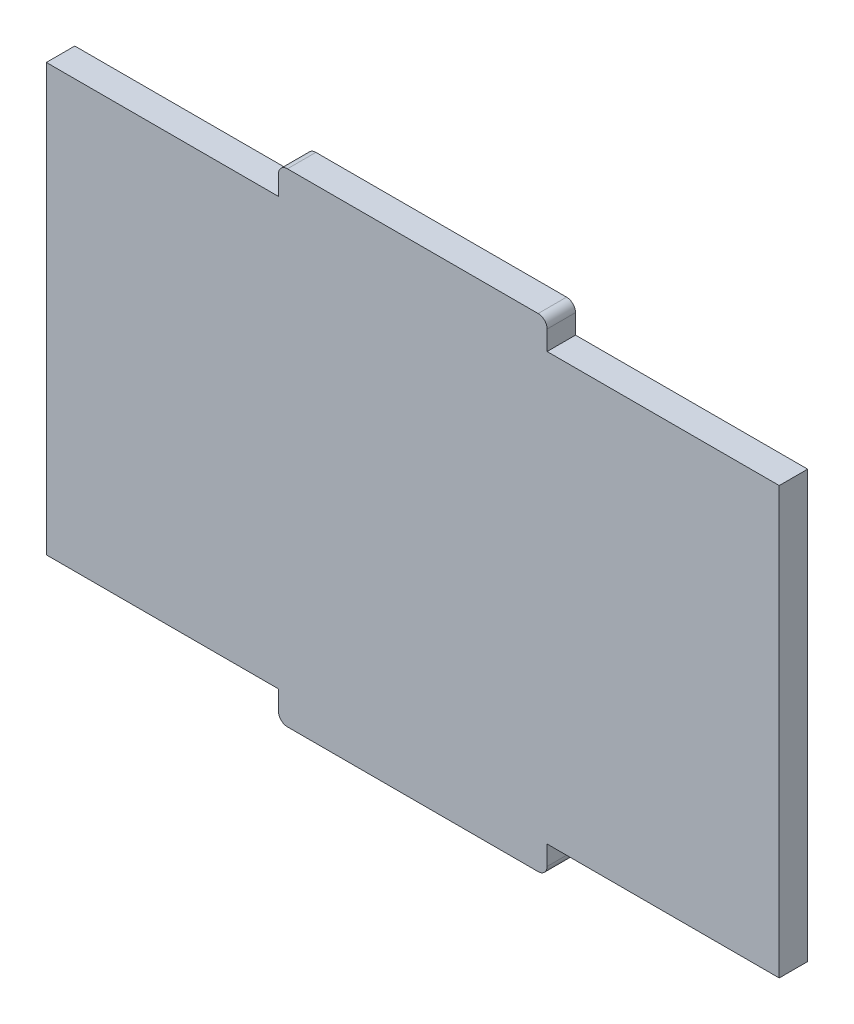
from build123d import *

# Parameters (mm, degrees)
BOSS_EXTRUDE1_DEPTH = 3.175
FILLET1_R           = 1


with BuildPart() as part:
    # Sketch1 → Boss-Extrude1 (new body)
    with BuildSketch(Plane.XY):
        Polygon((-40.925, -23.815), (-15, -23.815), (-15, -26.99), (15, -26.99), (15, -23.815), (40.925, -23.815), (40.925, 23.815), (15, 23.815), (15, 26.99), (-15, 26.99), (-15, 23.815), (-40.925, 23.815), align=None)
    extrude(amount=BOSS_EXTRUDE1_DEPTH)

    # Fillet1
    fillet1_edges = [part.edges().sort_by_distance(p)[0] for p in [
        (-15, -26.99, 1.5875),
        (15, -26.99, 1.5875),
        (15, 26.99, 1.5875),
        (-15, 26.99, 1.5875),
    ]]
    fillet(fillet1_edges, radius=FILLET1_R)


solid = part.part
